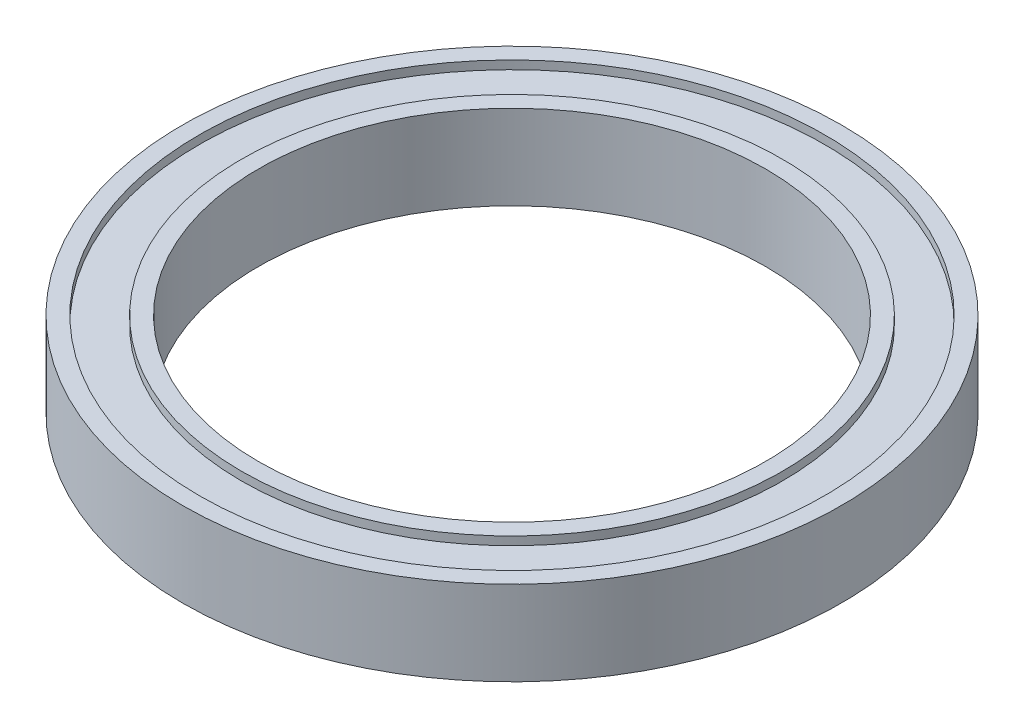
from build123d import *

# Parameters (mm, degrees)
SKETCH1_R           = 39
SKETCH1_R_2         = 30
BOSS_EXTRUDE1_DEPTH = 10
SKETCH2_R           = 37
SKETCH2_R_2         = 32
CUT_EXTRUDE1_DEPTH  = 1
SKETCH3_R           = 37
SKETCH3_R_2         = 32
CUT_EXTRUDE2_DEPTH  = 1


with BuildPart() as part:
    # Sketch1 → Boss-Extrude1 (new body)
    with BuildSketch(Plane(origin=(0, 0, 0), x_dir=(1, 0, 0), z_dir=(0, 1, 0))):
        Circle(SKETCH1_R)
        Circle(SKETCH1_R_2, mode=Mode.SUBTRACT)
    extrude(amount=BOSS_EXTRUDE1_DEPTH)

    # Sketch2 → Cut-Extrude1 (cut)
    with BuildSketch(Plane(origin=(0, 10, 0), x_dir=(1, 0, 0), z_dir=(0, 1, 0))):
        Circle(SKETCH2_R)
        Circle(SKETCH2_R_2, mode=Mode.SUBTRACT)
    extrude(amount=-CUT_EXTRUDE1_DEPTH, mode=Mode.SUBTRACT)

    # Sketch3 → Cut-Extrude2 (cut)
    with BuildSketch(Plane.XZ):
        Circle(SKETCH3_R)
        Circle(SKETCH3_R_2, mode=Mode.SUBTRACT)
    extrude(amount=-CUT_EXTRUDE2_DEPTH, mode=Mode.SUBTRACT)


solid = part.part
